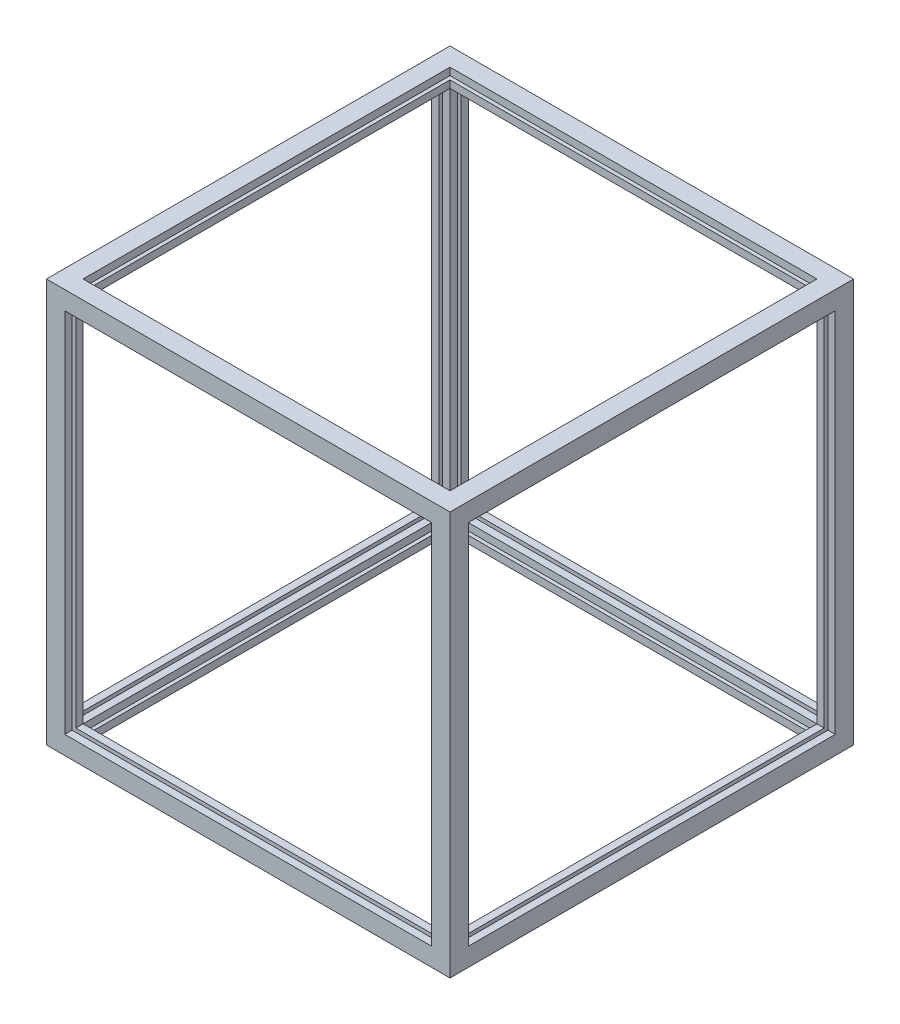
from build123d import *

# Parameters (mm, degrees)
CROQUIS1_W            = 220
CROQUIS1_H            = 220
CROQUIS1_W_2          = 200
CROQUIS1_H_2          = 200
MARCOBASE_DEPTH       = 10
CROQUIS2_W            = 10
CROQUIS2_H            = 10
PILARES_DEPTH         = 210
CROQUIS3_W            = 220
CROQUIS3_H            = 220
CROQUIS3_W_2          = 200
CROQUIS3_H_2          = 200
EXTERIOR_DEPTH        = 10
CROQUIS8_W            = 212
CROQUIS8_H            = 212
CROQUIS8_W_2          = 208
CROQUIS8_H_2          = 208
CORTAR_EXTRUIR5_DEPTH = 5
MATRIZC1_COUNT        = 4
MATRIZC2_COUNT        = 4


with BuildPart() as part:
    # Croquis1 → MarcoBase (new body)
    with BuildSketch(Plane.XY):
        with Locations((110, 110)):
            Rectangle(CROQUIS1_W, CROQUIS1_H)
        with Locations((110, 110)):
            Rectangle(CROQUIS1_W_2, CROQUIS1_H_2, mode=Mode.SUBTRACT)
    extrude(amount=MARCOBASE_DEPTH)

    # Croquis2 → Pilares (add)
    with BuildSketch(Plane.XY.offset(10)):
        with Locations((5, 215)):
            Rectangle(CROQUIS2_W, CROQUIS2_H)
        with Locations((215, 215)):
            Rectangle(CROQUIS2_W, CROQUIS2_H)
        with Locations((215, 5)):
            Rectangle(CROQUIS2_W, CROQUIS2_H)
        with Locations((5, 5)):
            Rectangle(CROQUIS2_W, CROQUIS2_H)
    extrude(amount=PILARES_DEPTH)

    # Croquis3 → Exterior (add)
    with BuildSketch(Plane.XY.offset(220)):
        with Locations((110, 110)):
            Rectangle(CROQUIS3_W, CROQUIS3_H)
        with Locations((110, 110)):
            Rectangle(CROQUIS3_W_2, CROQUIS3_H_2, mode=Mode.SUBTRACT)
    extrude(amount=-EXTERIOR_DEPTH)

    # Croquis8 → Cortar-Extruir5 (cut)
    with BuildSketch(Plane.XY.offset(10)):
        with Locations((110, 110)):
            Rectangle(CROQUIS8_W, CROQUIS8_H)
        with Locations((110, 110)):
            Rectangle(CROQUIS8_W_2, CROQUIS8_H_2, mode=Mode.SUBTRACT)
    cortar_extruir5 = extrude(amount=-CORTAR_EXTRUIR5_DEPTH, mode=Mode.SUBTRACT)

    # MatrizC1: Cortar-Extruir5 ×4 about axis
    matrizc1_axis = Axis((262.5, 110, 110), (-1, 0, 0))
    for i in range(1, MATRIZC1_COUNT):
        add(cortar_extruir5.rotate(matrizc1_axis, i * 360 / MATRIZC1_COUNT), mode=Mode.SUBTRACT)

    # MatrizC2: Cortar-Extruir5 ×4 about axis
    matrizc2_axis = Axis((110, 262.5, 110), (0, -1, 0))
    for i in range(1, MATRIZC2_COUNT):
        add(cortar_extruir5.rotate(matrizc2_axis, i * 360 / MATRIZC2_COUNT), mode=Mode.SUBTRACT)


solid = part.part
